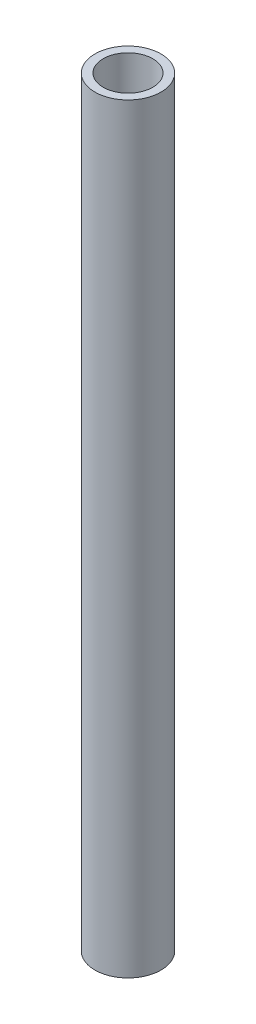
from build123d import *

# Parameters (mm, degrees)
SKETCH1_R           = 12.7
SKETCH1_R_2         = 9.525
BOSS_EXTRUDE1_DEPTH = 292.1


with BuildPart() as part:
    # Sketch1 → Boss-Extrude1 (new body)
    with BuildSketch(Plane(origin=(0, 0, 0), x_dir=(1, 0, 0), z_dir=(0, 1, 0))):
        Circle(SKETCH1_R)
        Circle(SKETCH1_R_2, mode=Mode.SUBTRACT)
    extrude(amount=BOSS_EXTRUDE1_DEPTH)


solid = part.part
